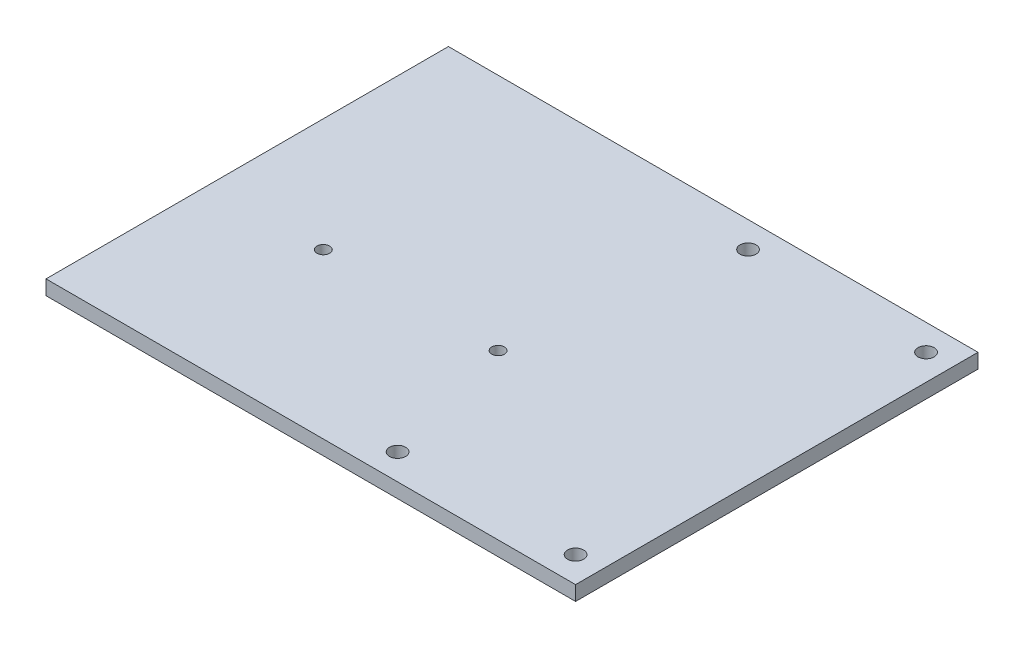
from build123d import *

# Parameters (mm, degrees)
SKETCH1_W           = 230.3
SKETCH1_H           = 175
SKETCH1_R           = 3.5
SKETCH1_R_2         = 2.75
BOSS_EXTRUDE1_DEPTH = 6.35


with BuildPart() as part:
    # Sketch1 → Boss-Extrude1 (new body)
    with BuildSketch(Plane(origin=(0, 0, 0), x_dir=(1, 0, 0), z_dir=(0, 1, 0))):
        with Locations((-115.15, -87.5)):
            Rectangle(SKETCH1_W, SKETCH1_H)
        with Locations((-88.7, -163.7)):
            Circle(SKETCH1_R, mode=Mode.SUBTRACT)
        with Locations((-11.3, -163.7)):
            Circle(SKETCH1_R, mode=Mode.SUBTRACT)
        with Locations((-11.3, -11.3)):
            Circle(SKETCH1_R, mode=Mode.SUBTRACT)
        with Locations((-88.7, -11.3)):
            Circle(SKETCH1_R, mode=Mode.SUBTRACT)
        with Locations((-105, -103.7)):
            Circle(SKETCH1_R_2, mode=Mode.SUBTRACT)
        with Locations((-181, -103.7)):
            Circle(SKETCH1_R_2, mode=Mode.SUBTRACT)
    extrude(amount=BOSS_EXTRUDE1_DEPTH)


solid = part.part
